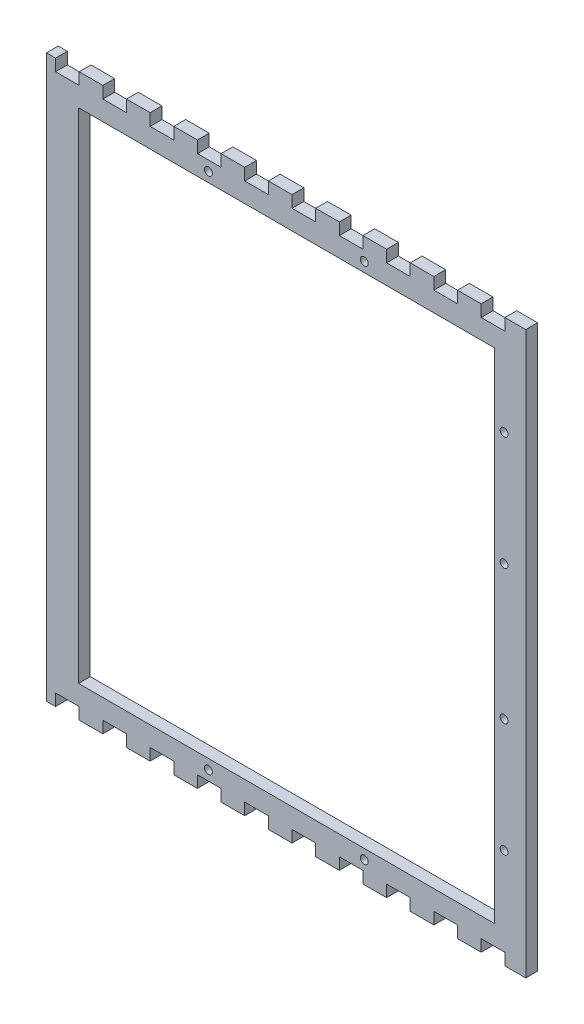
from build123d import *

# Parameters (mm, degrees)
BOSS_EXTRUDE1_DEPTH                               = 5.715
SKETCH1_W                                         = 201
SKETCH1_H                                         = 241
CUT_EXTRUDE1_DEPTH                                = 6.715
CSK_FOR_6_FLAT_HEAD_MACHINE_SCREW_100_D           = 3.7973
CSK_FOR_6_FLAT_HEAD_MACHINE_SCREW_100_CSINK_D     = 7.0866
CSK_FOR_6_FLAT_HEAD_MACHINE_SCREW_100_CSINK_ANGLE = 100
CSK_FOR_6_FLAT_HEAD_MACHINE_SCREW_2_D             = 3.7973
CSK_FOR_6_FLAT_HEAD_MACHINE_SCREW_2_CSINK_D       = 7.0866
CSK_FOR_6_FLAT_HEAD_MACHINE_SCREW_2_CSINK_ANGLE   = 100


with BuildPart() as part:
    # Model → Boss-Extrude1 (new body)
    with BuildSketch(Plane.XY):
        Polygon((1148.22, 22.8575), (1152.62, 22.8575), (1152.62, 28.5722), (1164.05, 28.5722), (1164.05, 22.8575), (1175.48, 22.8575), (1175.48, 28.5722), (1186.91, 28.5722), (1186.91, 22.8575), (1198.34, 22.8575), (1198.34, 28.5722), (1209.77, 28.5722), (1209.77, 22.8575), (1221.2, 22.8575), (1221.2, 28.5722), (1232.63, 28.5722), (1232.63, 22.8575), (1244.06, 22.8575), (1244.06, 28.5722), (1255.49, 28.5722), (1255.49, 22.8575), (1266.92, 22.8575), (1266.92, 28.5722), (1278.35, 28.5722), (1278.35, 22.8575), (1289.78, 22.8575), (1289.78, 28.5722), (1301.21, 28.5722), (1301.21, 22.8575), (1312.64, 22.8575), (1312.64, 28.5722), (1324.07, 28.5722), (1324.07, 22.8575), (1335.5, 22.8575), (1335.5, 28.5722), (1346.93, 28.5722), (1346.93, 22.8575), (1358.36, 22.8575), (1358.36, 28.5722), (1369.79, 28.5722), (1369.79, 22.8575), (1374.18, 22.8575), (1379.9, 22.8575), (1379.9, 28.5722), (1379.9, 288.572), (1379.9, 294.287), (1374.18, 294.287), (1369.79, 294.287), (1369.79, 288.572), (1358.36, 288.572), (1358.36, 294.287), (1346.93, 294.287), (1346.93, 288.572), (1335.5, 288.572), (1335.5, 294.287), (1324.07, 294.287), (1324.07, 288.572), (1312.64, 288.572), (1312.64, 294.287), (1301.21, 294.287), (1301.21, 288.572), (1289.78, 288.572), (1289.78, 294.287), (1278.35, 294.287), (1278.35, 288.572), (1266.92, 288.572), (1266.92, 294.287), (1255.49, 294.287), (1255.49, 288.572), (1244.06, 288.572), (1244.06, 294.287), (1232.63, 294.287), (1232.63, 288.572), (1221.2, 288.572), (1221.2, 294.287), (1209.77, 294.287), (1209.77, 288.572), (1198.34, 288.572), (1198.34, 294.287), (1186.91, 294.287), (1186.91, 288.572), (1175.48, 288.572), (1175.48, 294.287), (1164.05, 294.287), (1164.05, 288.572), (1152.62, 288.572), (1152.62, 294.287), (1148.22, 294.287), (1148.22, 288.572), (1148.22, 28.5722), align=None)
    extrude(amount=BOSS_EXTRUDE1_DEPTH)

    # Sketch1 → Cut-Extrude1 (cut, through all)
    with BuildSketch(Plane(origin=(0, 0, 0), x_dir=(-1, 0, 0), z_dir=(0, 0, -1))):
        with Locations((-1264.185, 158.57225)):
            Rectangle(SKETCH1_W, SKETCH1_H)
    extrude(amount=-CUT_EXTRUDE1_DEPTH, mode=Mode.SUBTRACT)

    # CSK for _6 Flat Head Machine Screw _100 (through all)
    with Locations(Plane(origin=(0, 0, 0), x_dir=(-1, 0, 0), z_dir=(0, 0, -1))):
        with Locations((-1301.85166666, 283.822125), (-1226.51833334, 283.822125), (-1226.51833334, 33.322375), (-1301.85166666, 33.322375)):
            CounterSinkHole(CSK_FOR_6_FLAT_HEAD_MACHINE_SCREW_100_D / 2, CSK_FOR_6_FLAT_HEAD_MACHINE_SCREW_100_CSINK_D / 2, counter_sink_angle=CSK_FOR_6_FLAT_HEAD_MACHINE_SCREW_100_CSINK_ANGLE)

    # CSK for _6 Flat Head Machine Screw _ 2 (through all)
    with Locations(Plane(origin=(0, 0, 0), x_dir=(-1, 0, 0), z_dir=(0, 0, -1))):
        with Locations((-1369.435, 246.0721), (-1369.435, 191.0721), (-1369.435, 126.0721), (-1369.435, 71.0721)):
            CounterSinkHole(CSK_FOR_6_FLAT_HEAD_MACHINE_SCREW_2_D / 2, CSK_FOR_6_FLAT_HEAD_MACHINE_SCREW_2_CSINK_D / 2, counter_sink_angle=CSK_FOR_6_FLAT_HEAD_MACHINE_SCREW_2_CSINK_ANGLE)


solid = part.part
